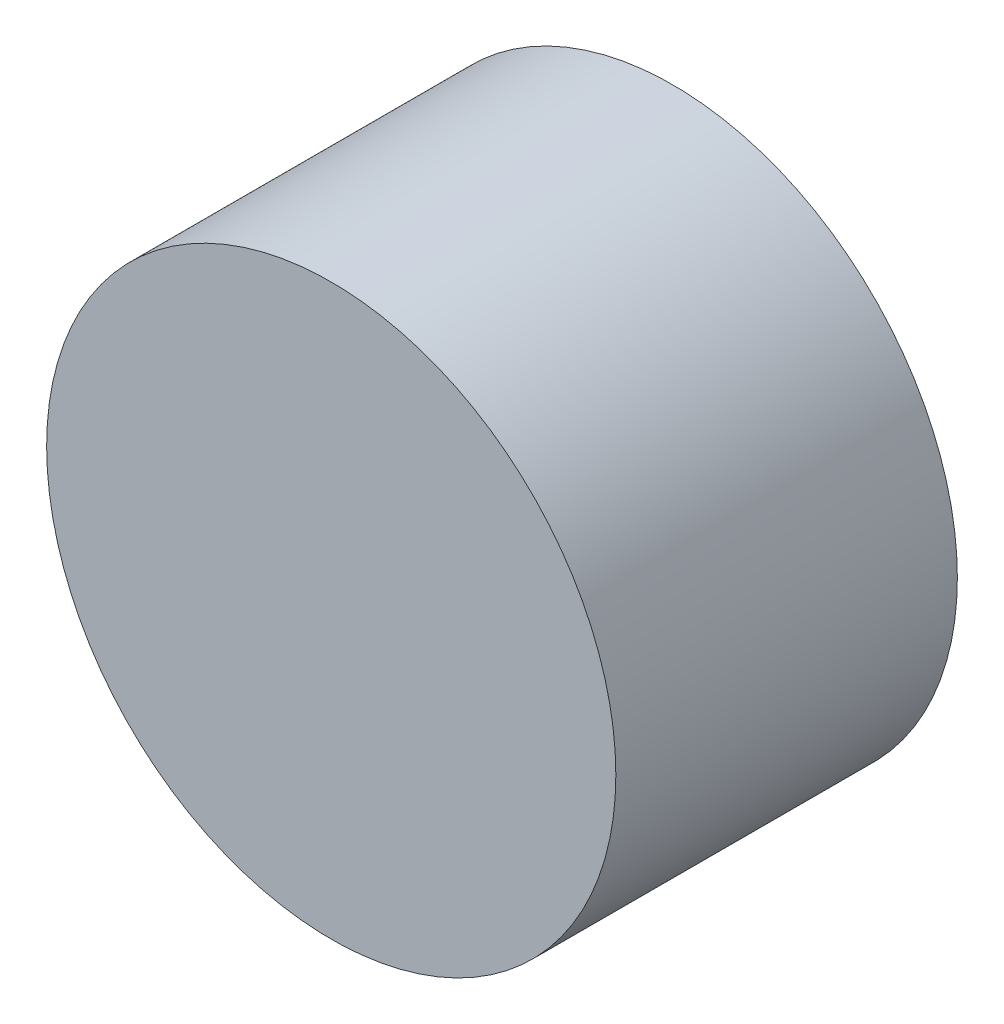
from build123d import *

# Parameters (mm, degrees)
SKETCH1_R           = 2.5
BOSS_EXTRUDE1_DEPTH = 1.5


with BuildPart() as part:
    # Sketch1 → Boss-Extrude1 (new body, symmetric)
    with BuildSketch(Plane.XY):
        Circle(SKETCH1_R)
    extrude(amount=BOSS_EXTRUDE1_DEPTH, both=True)


solid = part.part
